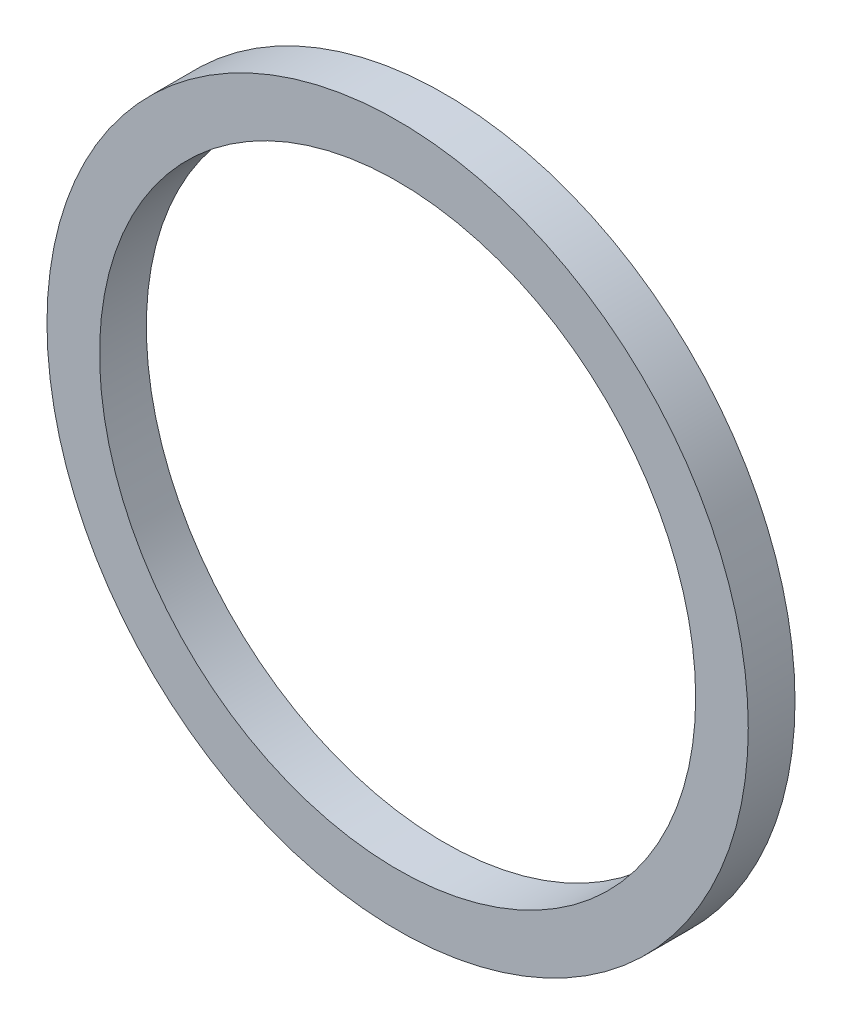
from build123d import *

# Parameters (mm, degrees)
SKIZZE1_R                       = 15
SKIZZE1_R_2                     = 12.75
AUFSATZ_LINEAR_AUSTRAGEN1_DEPTH = 2


with BuildPart() as part:
    # Skizze1 → Aufsatz-Linear austragen1 (new body)
    with BuildSketch(Plane.XY):
        Circle(SKIZZE1_R)
        Circle(SKIZZE1_R_2, mode=Mode.SUBTRACT)
    extrude(amount=AUFSATZ_LINEAR_AUSTRAGEN1_DEPTH)


solid = part.part
